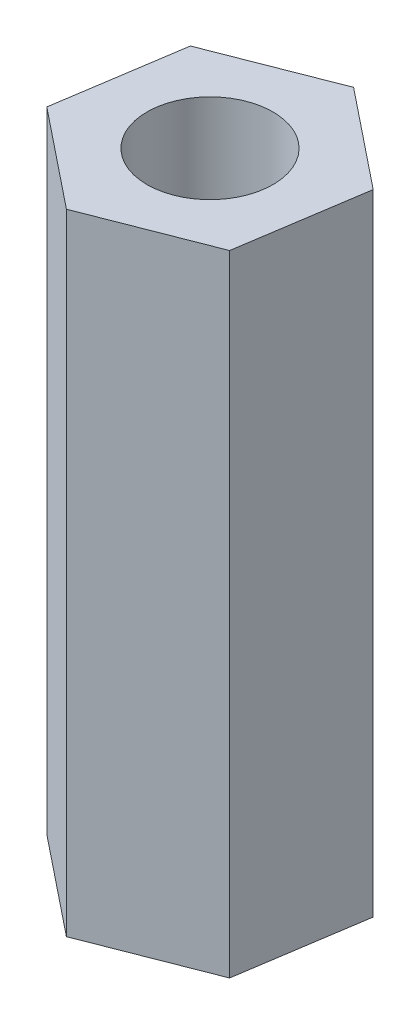
from build123d import *

# Parameters (mm, degrees)
BOSS_EXTRUDE1_DEPTH = 15
SKETCH2_R           = 1.5
CUT_EXTRUDE1_DEPTH  = 16


with BuildPart() as part:
    # Sketch1 → Boss-Extrude1 (new body)
    with BuildSketch(Plane(origin=(0, 0, 0), x_dir=(1, 0, 0), z_dir=(0, 1, 0))):
        Polygon((2.794734757, 1.090622592), (0.452860507, 2.965622592), (-2.341874249, 1.875), (-2.794734757, -1.090622592), (-0.452860507, -2.965622592), (2.341874249, -1.875), align=None)
    extrude(amount=-BOSS_EXTRUDE1_DEPTH)

    # Sketch2 → Cut-Extrude1 (cut, through all)
    with BuildSketch(Plane(origin=(0, 0, 0), x_dir=(1, 0, 0), z_dir=(0, 1, 0))):
        Circle(SKETCH2_R)
    extrude(amount=-CUT_EXTRUDE1_DEPTH, mode=Mode.SUBTRACT)


solid = part.part
